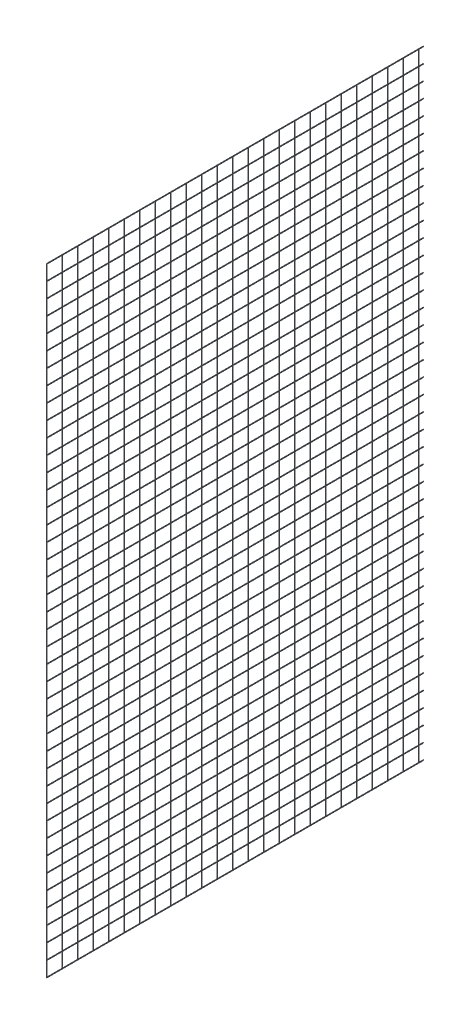
from build123d import *

# Parameters (mm, degrees)
SKETCH2_R       = 1.5
LPATTERN3_COUNT = 42
LPATTERN3_PITCH = 80
SKETCH10_R      = 1.5
LPATTERN4_COUNT = 25
LPATTERN4_PITCH = 82.24


with BuildPart() as part:
    # Sweep2: sweep along a path in Sketch1
    with BuildLine(Plane(origin=(0, 0, 0), x_dir=(1, 0, 0), z_dir=(0, 1, 0))) as sweep2_path:
        Line((0, 0), (0, 2000))
    # Sketch2 → Sweep2 (sweep)
    with BuildSketch(Plane.XY):
        Circle(SKETCH2_R)
    sweep(path=sweep2_path.line)


with BuildPart() as lpattern3_1:
    # LPattern3: pattern copy
    add(part.part.moved(Location(Vector(0, 1, 0) * (1 * LPATTERN3_PITCH))))


with BuildPart() as lpattern3_2:
    # LPattern3: pattern copy
    add(part.part.moved(Location(Vector(0, 1, 0) * (2 * LPATTERN3_PITCH))))


with BuildPart() as lpattern3_3:
    # LPattern3: pattern copy
    add(part.part.moved(Location(Vector(0, 1, 0) * (3 * LPATTERN3_PITCH))))


with BuildPart() as lpattern3_4:
    # LPattern3: pattern copy
    add(part.part.moved(Location(Vector(0, 1, 0) * (4 * LPATTERN3_PITCH))))


with BuildPart() as lpattern3_5:
    # LPattern3: pattern copy
    add(part.part.moved(Location(Vector(0, 1, 0) * (5 * LPATTERN3_PITCH))))


with BuildPart() as lpattern3_6:
    # LPattern3: pattern copy
    add(part.part.moved(Location(Vector(0, 1, 0) * (6 * LPATTERN3_PITCH))))


with BuildPart() as lpattern3_7:
    # LPattern3: pattern copy
    add(part.part.moved(Location(Vector(0, 1, 0) * (7 * LPATTERN3_PITCH))))


with BuildPart() as lpattern3_8:
    # LPattern3: pattern copy
    add(part.part.moved(Location(Vector(0, 1, 0) * (8 * LPATTERN3_PITCH))))


with BuildPart() as lpattern3_9:
    # LPattern3: pattern copy
    add(part.part.moved(Location(Vector(0, 1, 0) * (9 * LPATTERN3_PITCH))))


with BuildPart() as lpattern3_10:
    # LPattern3: pattern copy
    add(part.part.moved(Location(Vector(0, 1, 0) * (10 * LPATTERN3_PITCH))))


with BuildPart() as lpattern3_11:
    # LPattern3: pattern copy
    add(part.part.moved(Location(Vector(0, 1, 0) * (11 * LPATTERN3_PITCH))))


with BuildPart() as lpattern3_12:
    # LPattern3: pattern copy
    add(part.part.moved(Location(Vector(0, 1, 0) * (12 * LPATTERN3_PITCH))))


with BuildPart() as lpattern3_13:
    # LPattern3: pattern copy
    add(part.part.moved(Location(Vector(0, 1, 0) * (13 * LPATTERN3_PITCH))))


with BuildPart() as lpattern3_14:
    # LPattern3: pattern copy
    add(part.part.moved(Location(Vector(0, 1, 0) * (14 * LPATTERN3_PITCH))))


with BuildPart() as lpattern3_15:
    # LPattern3: pattern copy
    add(part.part.moved(Location(Vector(0, 1, 0) * (15 * LPATTERN3_PITCH))))


with BuildPart() as lpattern3_16:
    # LPattern3: pattern copy
    add(part.part.moved(Location(Vector(0, 1, 0) * (16 * LPATTERN3_PITCH))))


with BuildPart() as lpattern3_17:
    # LPattern3: pattern copy
    add(part.part.moved(Location(Vector(0, 1, 0) * (17 * LPATTERN3_PITCH))))


with BuildPart() as lpattern3_18:
    # LPattern3: pattern copy
    add(part.part.moved(Location(Vector(0, 1, 0) * (18 * LPATTERN3_PITCH))))


with BuildPart() as lpattern3_19:
    # LPattern3: pattern copy
    add(part.part.moved(Location(Vector(0, 1, 0) * (19 * LPATTERN3_PITCH))))


with BuildPart() as lpattern3_20:
    # LPattern3: pattern copy
    add(part.part.moved(Location(Vector(0, 1, 0) * (20 * LPATTERN3_PITCH))))


with BuildPart() as lpattern3_21:
    # LPattern3: pattern copy
    add(part.part.moved(Location(Vector(0, 1, 0) * (21 * LPATTERN3_PITCH))))


with BuildPart() as lpattern3_22:
    # LPattern3: pattern copy
    add(part.part.moved(Location(Vector(0, 1, 0) * (22 * LPATTERN3_PITCH))))


with BuildPart() as lpattern3_23:
    # LPattern3: pattern copy
    add(part.part.moved(Location(Vector(0, 1, 0) * (23 * LPATTERN3_PITCH))))


with BuildPart() as lpattern3_24:
    # LPattern3: pattern copy
    add(part.part.moved(Location(Vector(0, 1, 0) * (24 * LPATTERN3_PITCH))))


with BuildPart() as lpattern3_25:
    # LPattern3: pattern copy
    add(part.part.moved(Location(Vector(0, 1, 0) * (25 * LPATTERN3_PITCH))))


with BuildPart() as lpattern3_26:
    # LPattern3: pattern copy
    add(part.part.moved(Location(Vector(0, 1, 0) * (26 * LPATTERN3_PITCH))))


with BuildPart() as lpattern3_27:
    # LPattern3: pattern copy
    add(part.part.moved(Location(Vector(0, 1, 0) * (27 * LPATTERN3_PITCH))))


with BuildPart() as lpattern3_28:
    # LPattern3: pattern copy
    add(part.part.moved(Location(Vector(0, 1, 0) * (28 * LPATTERN3_PITCH))))


with BuildPart() as lpattern3_29:
    # LPattern3: pattern copy
    add(part.part.moved(Location(Vector(0, 1, 0) * (29 * LPATTERN3_PITCH))))


with BuildPart() as lpattern3_30:
    # LPattern3: pattern copy
    add(part.part.moved(Location(Vector(0, 1, 0) * (30 * LPATTERN3_PITCH))))


with BuildPart() as lpattern3_31:
    # LPattern3: pattern copy
    add(part.part.moved(Location(Vector(0, 1, 0) * (31 * LPATTERN3_PITCH))))


with BuildPart() as lpattern3_32:
    # LPattern3: pattern copy
    add(part.part.moved(Location(Vector(0, 1, 0) * (32 * LPATTERN3_PITCH))))


with BuildPart() as lpattern3_33:
    # LPattern3: pattern copy
    add(part.part.moved(Location(Vector(0, 1, 0) * (33 * LPATTERN3_PITCH))))


with BuildPart() as lpattern3_34:
    # LPattern3: pattern copy
    add(part.part.moved(Location(Vector(0, 1, 0) * (34 * LPATTERN3_PITCH))))


with BuildPart() as lpattern3_35:
    # LPattern3: pattern copy
    add(part.part.moved(Location(Vector(0, 1, 0) * (35 * LPATTERN3_PITCH))))


with BuildPart() as lpattern3_36:
    # LPattern3: pattern copy
    add(part.part.moved(Location(Vector(0, 1, 0) * (36 * LPATTERN3_PITCH))))


with BuildPart() as lpattern3_37:
    # LPattern3: pattern copy
    add(part.part.moved(Location(Vector(0, 1, 0) * (37 * LPATTERN3_PITCH))))


with BuildPart() as lpattern3_38:
    # LPattern3: pattern copy
    add(part.part.moved(Location(Vector(0, 1, 0) * (38 * LPATTERN3_PITCH))))


with BuildPart() as lpattern3_39:
    # LPattern3: pattern copy
    add(part.part.moved(Location(Vector(0, 1, 0) * (39 * LPATTERN3_PITCH))))


with BuildPart() as lpattern3_40:
    # LPattern3: pattern copy
    add(part.part.moved(Location(Vector(0, 1, 0) * (40 * LPATTERN3_PITCH))))


with BuildPart() as lpattern3_41:
    # LPattern3: pattern copy
    add(part.part.moved(Location(Vector(0, 1, 0) * (41 * LPATTERN3_PITCH))))


with BuildPart() as part_1:
    add(part.part)

    add(lpattern3_1.part)  # Sweep3 merges LPattern3_1

    add(lpattern3_2.part)  # Sweep3 merges LPattern3_2

    add(lpattern3_3.part)  # Sweep3 merges LPattern3_3

    add(lpattern3_4.part)  # Sweep3 merges LPattern3_4

    add(lpattern3_5.part)  # Sweep3 merges LPattern3_5

    add(lpattern3_6.part)  # Sweep3 merges LPattern3_6

    add(lpattern3_7.part)  # Sweep3 merges LPattern3_7

    add(lpattern3_8.part)  # Sweep3 merges LPattern3_8

    add(lpattern3_9.part)  # Sweep3 merges LPattern3_9

    add(lpattern3_10.part)  # Sweep3 merges LPattern3_10

    add(lpattern3_11.part)  # Sweep3 merges LPattern3_11

    add(lpattern3_12.part)  # Sweep3 merges LPattern3_12

    add(lpattern3_13.part)  # Sweep3 merges LPattern3_13

    add(lpattern3_14.part)  # Sweep3 merges LPattern3_14

    add(lpattern3_15.part)  # Sweep3 merges LPattern3_15

    add(lpattern3_16.part)  # Sweep3 merges LPattern3_16

    add(lpattern3_17.part)  # Sweep3 merges LPattern3_17

    add(lpattern3_18.part)  # Sweep3 merges LPattern3_18

    add(lpattern3_19.part)  # Sweep3 merges LPattern3_19

    add(lpattern3_20.part)  # Sweep3 merges LPattern3_20

    add(lpattern3_21.part)  # Sweep3 merges LPattern3_21
    # Sweep3: sweep along a path in Sketch9
    with BuildLine(Plane(origin=(0, 0, 0), x_dir=(0, 0, -1), z_dir=(1, 0, 0))) as sweep3_path:
        Line((1.5, 3280), (1.5, 0))
    # Sketch10 → Sweep3 (sweep)
    with BuildSketch(Plane(origin=(0, 0, 0), x_dir=(1, 0, 0), z_dir=(0, 1, 0))):
        with Locations((0, 1.5)):
            Circle(SKETCH10_R)
    sweep3 = sweep(path=sweep3_path.line)

    # LPattern4: Sweep3 ×25
    with Locations(*[(0, 0, -i * LPATTERN4_PITCH) for i in range(1, LPATTERN4_COUNT)]):
        add(sweep3)


solid = Compound([lpattern3_22.part, lpattern3_23.part, lpattern3_24.part, lpattern3_25.part, lpattern3_26.part, lpattern3_27.part, lpattern3_28.part, lpattern3_29.part, lpattern3_30.part, lpattern3_31.part, lpattern3_32.part, lpattern3_33.part, lpattern3_34.part, lpattern3_35.part, lpattern3_36.part, lpattern3_37.part, lpattern3_38.part, lpattern3_39.part, lpattern3_40.part, lpattern3_41.part, part_1.part])
